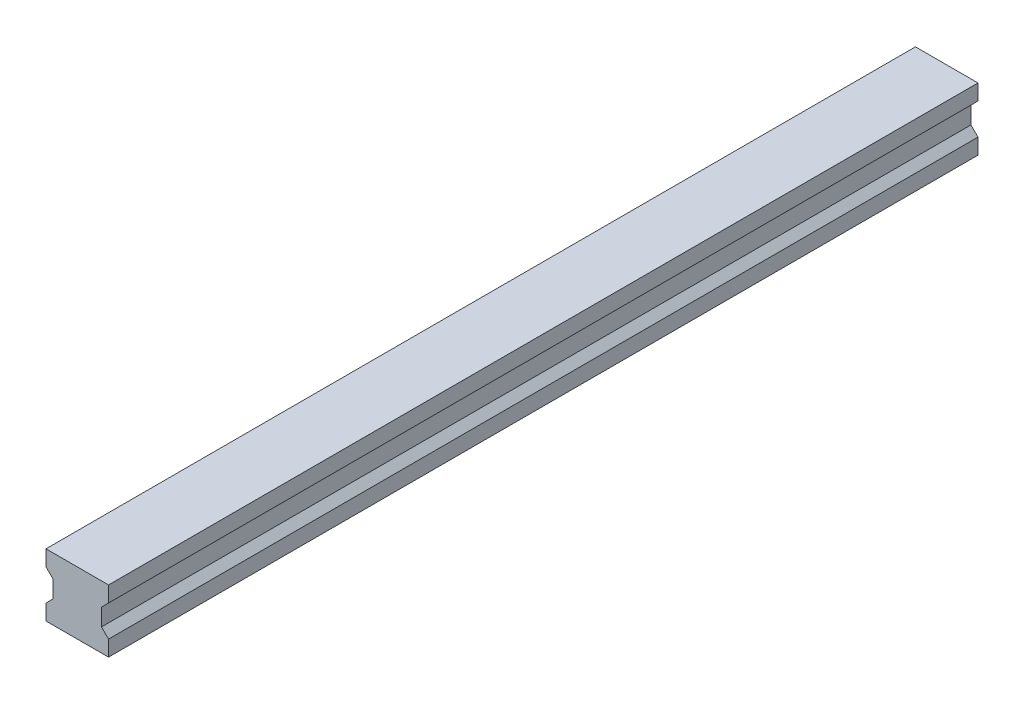
from build123d import *

# Parameters (mm, degrees)
BOSS_EXTRUDE1_DEPTH = 278


with BuildPart() as part:
    # Sketch1 → Boss-Extrude1 (new body)
    with BuildSketch(Plane.XY):
        Polygon((7.75, -2.75), (7.75, 2.75), (10, 5), (10, 10), (-10, 10), (-10, 4.999999106), (-7.75000459, 2.749999106), (-7.75000459, -2.749999106), (-10, -4.999999106), (-10, -10), (10, -10), (10, -5), align=None)
    extrude(amount=BOSS_EXTRUDE1_DEPTH)


solid = part.part
